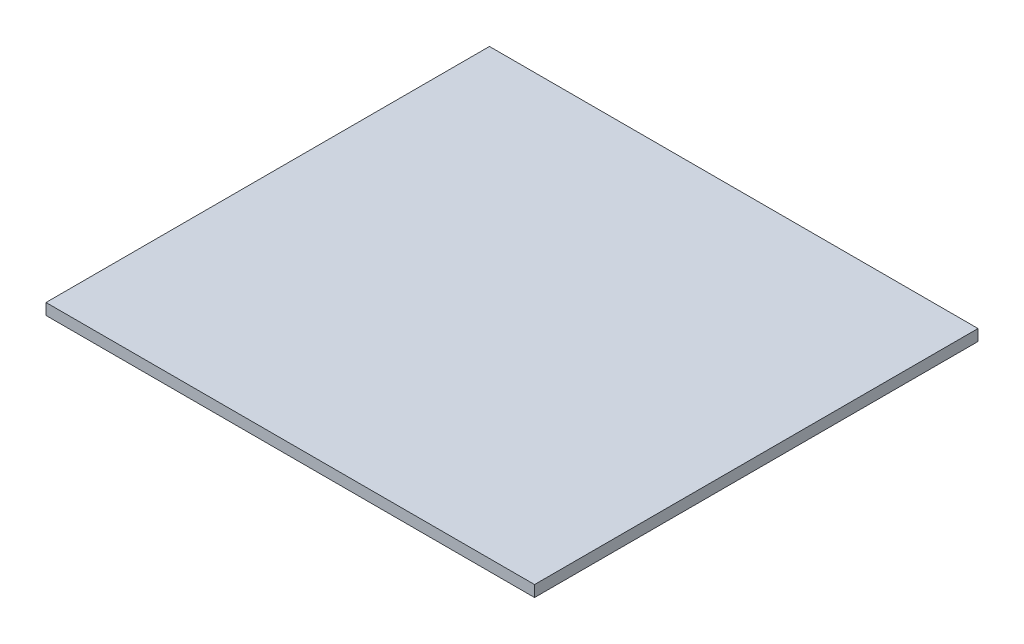
from build123d import *

# Parameters (mm, degrees)
SKETCH1_W           = 130
SKETCH1_H           = 118
BOSS_EXTRUDE2_DEPTH = 3


with BuildPart() as part:
    # Sketch1 → Boss-Extrude2 (new body)
    with BuildSketch(Plane(origin=(0, 0, 0), x_dir=(1, 0, 0), z_dir=(0, 1, 0))):
        with Locations((-41.132795848, 5.853856836)):
            Rectangle(SKETCH1_W, SKETCH1_H)
    extrude(amount=BOSS_EXTRUDE2_DEPTH)


solid = part.part
